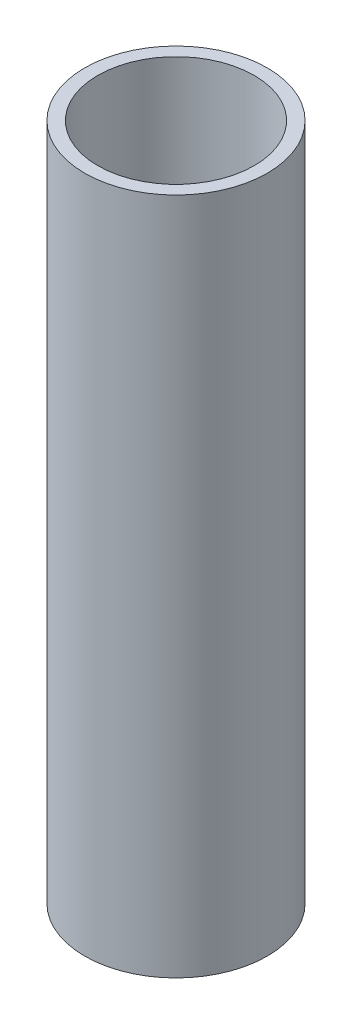
from build123d import *

# Parameters (mm, degrees)
SKETCH1_R           = 44.45
SKETCH1_R_2         = 38.1
BOSS_EXTRUDE1_DEPTH = 330.2


with BuildPart() as part:
    # Sketch1 → Boss-Extrude1 (new body)
    with BuildSketch(Plane(origin=(0, 0, 0), x_dir=(1, 0, 0), z_dir=(0, 1, 0))):
        Circle(SKETCH1_R)
        Circle(SKETCH1_R_2, mode=Mode.SUBTRACT)
    extrude(amount=BOSS_EXTRUDE1_DEPTH)


solid = part.part
